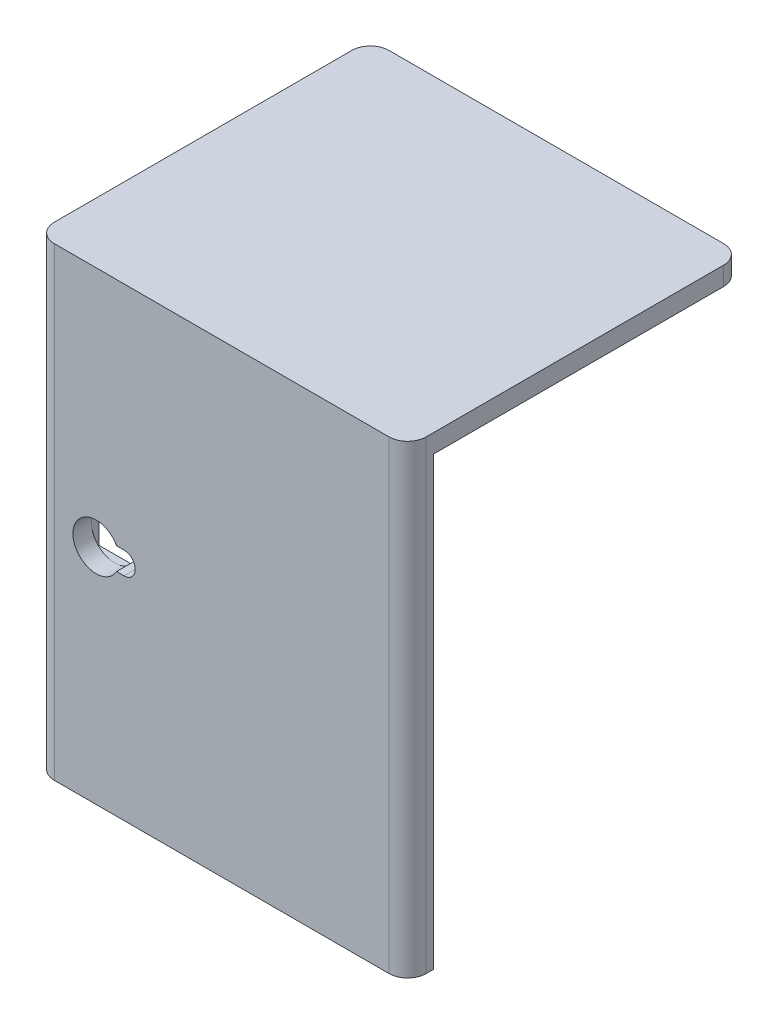
from build123d import *

# Parameters (mm, degrees)
SKETCH_1_W          = 100
SKETCH_1_H          = 90
EXTRUDE_1_DEPTH     = 125
SKETCH_4_W          = 100
SKETCH_4_H          = 83
CUT_EXTRUDE_3_DEPTH = 120
FILLET_4_R          = 5
CUT_EXTRUDE_4_DEPTH = 120
SKETCH_6_W          = 23
SKETCH_6_H          = 12.5
CUT_EXTRUDE_5_DEPTH = 2


with BuildPart() as part:
    # 스케치1 → 보스-돌출1 (new body)
    with BuildSketch(Plane(origin=(0, 0, 0), x_dir=(1, 0, 0), z_dir=(0, 1, 0))):
        Rectangle(SKETCH_1_W, SKETCH_1_H)
    extrude(amount=EXTRUDE_1_DEPTH)

    # 스케치4 → 컷-돌출3 (cut)
    with BuildSketch(Plane.XZ):
        with Locations((0, -3.5)):
            Rectangle(SKETCH_4_W, SKETCH_4_H)
    extrude(amount=-CUT_EXTRUDE_3_DEPTH, mode=Mode.SUBTRACT)

    # 필렛4
    fillet_4_edges = [part.edges().sort_by_distance(p)[0] for p in [
        (50, 62.5, 45),
        (-50, 62.5, 45),
        (-50, 122.5, -45),
        (50, 122.5, -45),
    ]]
    fillet(fillet_4_edges, radius=FILLET_4_R)

    # 스케치5 → 컷-돌출4 (cut)
    with BuildSketch(Plane(origin=(0, 0, 38), x_dir=(-1, 0, 0), z_dir=(0, 0, -1))):
        with BuildLine():
            Line((26.25, 63), (28.26707195, 63))
            ThreePointArc((28.26707195, 63), (40, 60), (28.26707195, 57))
            Line((28.26707195, 57), (26.25, 57))
            ThreePointArc((26.25, 57), (23.25, 60), (26.25, 63))
        make_face()
    extrude(amount=-CUT_EXTRUDE_4_DEPTH, mode=Mode.SUBTRACT)

    # 스케치6 → 컷-돌출5 (cut)
    with BuildSketch(Plane(origin=(0, 0, 38), x_dir=(-1, 0, 0), z_dir=(0, 0, -1))):
        with Locations((28.5, 60)):
            Rectangle(SKETCH_6_W, SKETCH_6_H)
    extrude(amount=-CUT_EXTRUDE_5_DEPTH, mode=Mode.SUBTRACT)


solid = part.part
